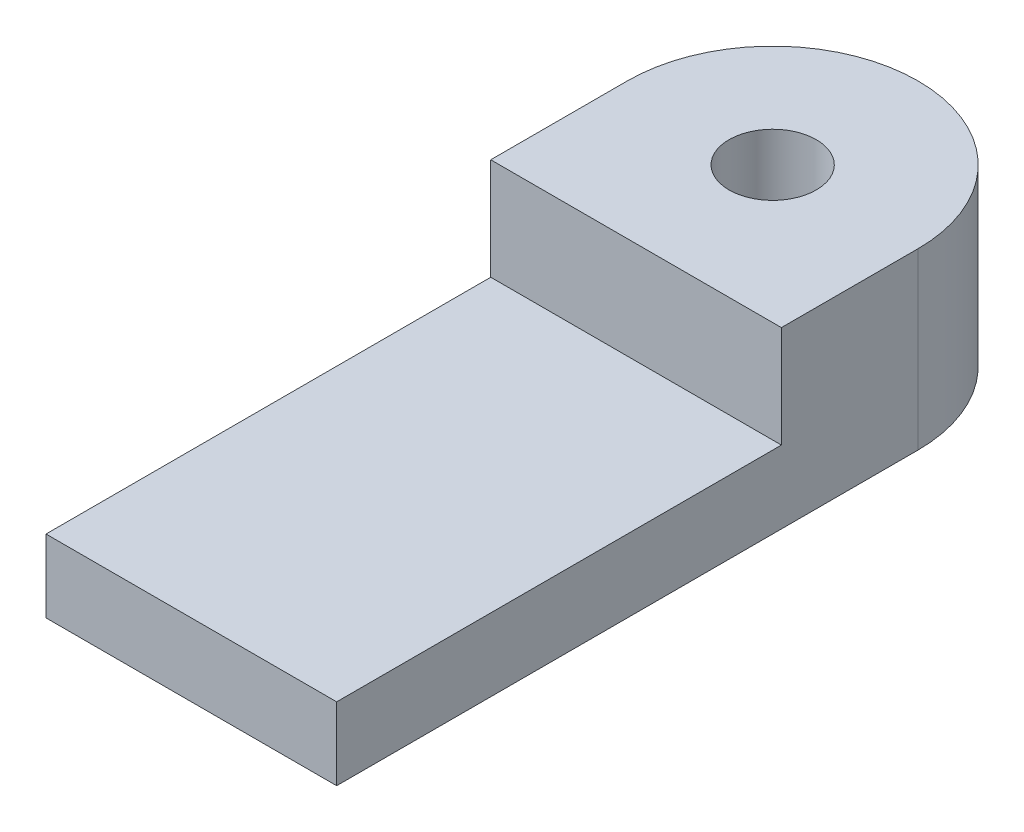
from build123d import *

# Parameters (mm, degrees)
AUFSATZ_LINEAR_AUSTRAGEN1_DEPTH = 2.5
AUFSATZ_LINEAR_AUSTRAGEN2_DEPTH = 3.5
SKIZZE3_R                       = 1.5
SCHNITT_LINEAR_AUSTRAGEN1_DEPTH = 7


with BuildPart() as part:
    # Skizze1 → Aufsatz-Linear austragen1 (new body)
    with BuildSketch(Plane(origin=(0, 0, 0), x_dir=(1, 0, 0), z_dir=(0, 1, 0))):
        with BuildLine():
            Line((0, 0), (0, 20))
            ThreePointArc((0, 20), (5, 25), (10, 20))
            Line((10, 20), (10, 0))
            Line((10, 0), (0, 0))
        make_face()
    extrude(amount=AUFSATZ_LINEAR_AUSTRAGEN1_DEPTH)

    # Skizze2 → Aufsatz-Linear austragen2 (add)
    with BuildSketch(Plane(origin=(0, 2.5, 0), x_dir=(1, 0, 0), z_dir=(0, 1, 0))):
        with BuildLine():
            Line((0, 20), (0, 15.3))
            Line((0, 15.3), (10, 15.3))
            Line((10, 15.3), (10, 20))
            ThreePointArc((10, 20), (5, 25), (0, 20))
        make_face()
    extrude(amount=AUFSATZ_LINEAR_AUSTRAGEN2_DEPTH)

    # Skizze3 → Schnitt-Linear austragen1 (cut, through all)
    with BuildSketch(Plane(origin=(0, 6, 0), x_dir=(1, 0, 0), z_dir=(0, 1, 0))):
        with Locations((5, 20)):
            Circle(SKIZZE3_R)
    extrude(amount=-SCHNITT_LINEAR_AUSTRAGEN1_DEPTH, mode=Mode.SUBTRACT)


solid = part.part
